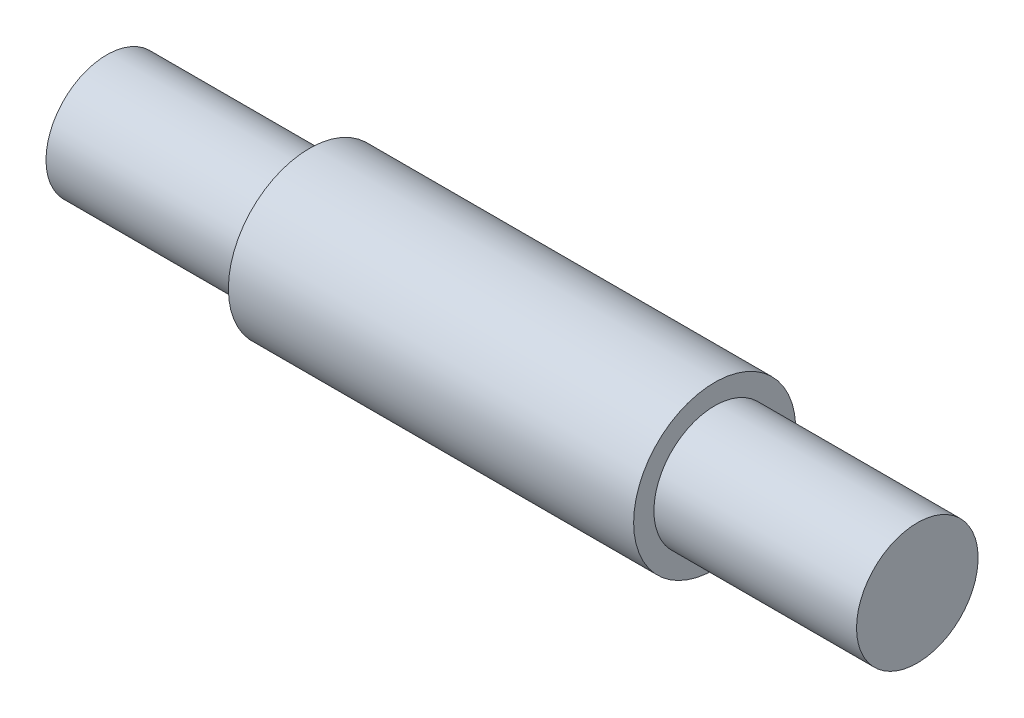
from build123d import *


with BuildPart() as part:
    # Sketch1 → Revolve1 (revolve)
    with BuildSketch(Plane.XY):
        Polygon((-40, 0), (40, 0), (40, 6), (20, 6), (20, 8), (-20, 8), (-20, 6), (-40, 6), align=None)
    revolve(axis=Axis((-50, 0, 0), (1, 0, 0)))


solid = part.part
